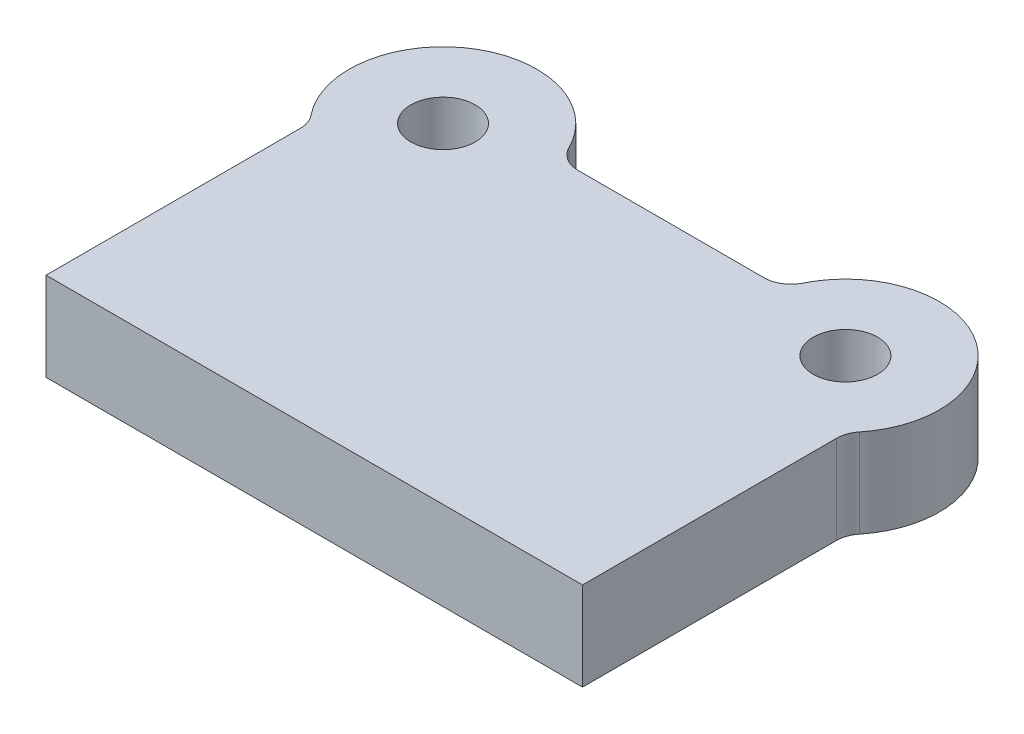
from build123d import *

# Parameters (mm, degrees)
SKETCH1_R           = 12
BOSS_EXTRUDE1_DEPTH = 33
FILLET1_R           = 10


with BuildPart() as part:
    # Sketch1 → Boss-Extrude1 (new body)
    with BuildSketch(Plane(origin=(0, 0, 0), x_dir=(1, 0, 0), z_dir=(0, 1, 0))):
        with BuildLine():
            Line((100, 0), (-100, 0))
            Line((-100, 0), (-100, 98.505102572))
            ThreePointArc((-100, 98.505102572), (-92.768279077, 153.154406952), (-41.458980338, 133))
            Line((-41.458980338, 133), (41.458980338, 133))
            ThreePointArc((41.458980338, 133), (92.768279077, 153.154406952), (100, 98.505102572))
            Line((100, 98.505102572), (100, 0))
        make_face()
        with Locations((-75, 123)):
            Circle(SKETCH1_R, mode=Mode.SUBTRACT)
        with Locations((75, 123)):
            Circle(SKETCH1_R, mode=Mode.SUBTRACT)
    extrude(amount=BOSS_EXTRUDE1_DEPTH)

    # Fillet1
    fillet1_edges = [part.edges().sort_by_distance(p)[0] for p in [
        (-100, 16.5, -98.505102572),
        (-41.458980338, 16.5, -133),
        (41.458980338, 16.5, -133),
        (100, 16.5, -98.505102572),
    ]]
    fillet(fillet1_edges, radius=FILLET1_R)


solid = part.part
